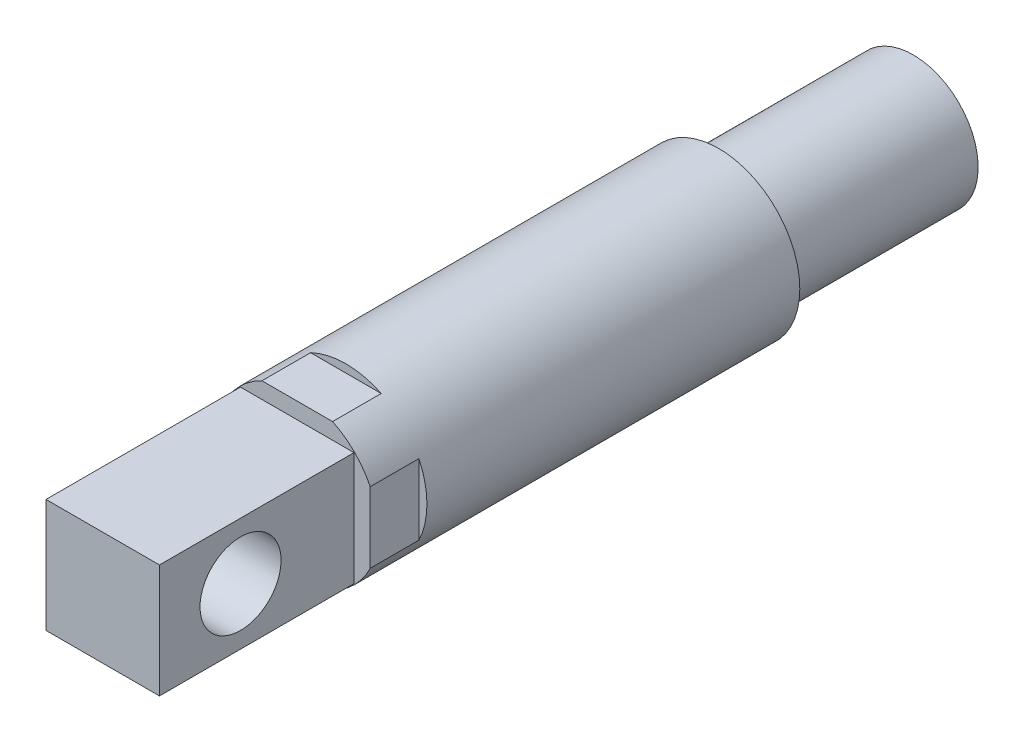
from build123d import *

# Parameters (mm, degrees)
ESQUISSE1_R             = 5
BOSS_EXTRU_2_DEPTH      = 70
ESQUISSE2_R             = 3.5
BOSS_EXTRU_3_DEPTH      = 12
ESQUISSE4_R             = 15
BOSS_EXTRU_5_DEPTH      = 5
ESQUISSE5_R             = 3.5
BOSS_EXTRU_6_DEPTH      = 12
ENL_V_MAT_EXTRU_1_DEPTH = 12
ESQUISSE7_R             = 15
ENL_V_MAT_EXTRU_2_DEPTH = 47
ESQUISSE8_W             = 9
ESQUISSE8_H             = 9
BOSS_EXTRU_7_DEPTH      = 5
ESQUISSE9_W             = 10
ESQUISSE9_H             = 10
ESQUISSE9_W_2           = 9
ESQUISSE9_H_2           = 9
ENL_V_MAT_EXTRU_3_DEPTH = 12
ESQUISSE10_W            = 9
ESQUISSE10_H            = 9
BOSS_EXTRU_8_DEPTH      = 7
ESQUISSE11_W            = 9
ESQUISSE11_H            = 9
ENL_V_MAT_EXTRU_4_DEPTH = 4
ESQUISSE13_W            = 9
ESQUISSE13_H            = 9
BOSS_EXTRU_9_DEPTH      = 12
ESQUISSE14_W            = 9
ESQUISSE14_H            = 9
ESQUISSE14_W_2          = 7
ESQUISSE14_H_2          = 7
ENL_V_MAT_EXTRU_5_DEPTH = 12
ESQUISSE15_R            = 2.5
ENL_V_MAT_EXTRU_6_DEPTH = 12
ESQUISSE16_R            = 4
BOSS_EXTRU_10_DEPTH     = 12


with BuildPart() as part:
    # Esquisse1 → Boss.-Extru.2 (new body)
    with BuildSketch(Plane.XY):
        Circle(ESQUISSE1_R)
    extrude(amount=BOSS_EXTRU_2_DEPTH)

    # Esquisse2 → Boss.-Extru.3 (add)
    with BuildSketch(Plane(origin=(0, 0, 0), x_dir=(-1, 0, 0), z_dir=(0, 0, -1))):
        Circle(ESQUISSE2_R)
    extrude(amount=BOSS_EXTRU_3_DEPTH)

    # Esquisse4 → Boss.-Extru.5 (add)
    with BuildSketch(Plane.XY.offset(70)):
        Circle(ESQUISSE4_R)
    extrude(amount=-BOSS_EXTRU_5_DEPTH)

    # Esquisse5 → Boss.-Extru.6 (add)
    with BuildSketch(Plane.XY.offset(70)):
        Circle(ESQUISSE5_R)
    extrude(amount=BOSS_EXTRU_6_DEPTH)

    # Esquisse6 → Enlèv. mat.-Extru.1 (cut)
    with BuildSketch(Plane.XY.offset(70)):
        with BuildLine():
            Line((-6.262893089, 8.172072336), (-7.499435292, 12.990707074))
            ThreePointArc((-7.499435292, 12.990707074), (-9.123657799, 11.90625333), (-10.593218546, 10.619968024))
            Line((-10.593218546, 10.619968024), (-6.262893089, 8.172072336))
        make_face()
        with BuildLine():
            Line((-8.152402023, 6.270263162), (-10.606442664, 10.606760769))
            ThreePointArc((-10.606442664, 10.606760769), (-11.894621233, 9.138817524), (-12.981158937, 7.515950549))
            Line((-12.981158937, 7.515950549), (-8.152402023, 6.270263162))
        make_face()
        with BuildLine():
            Line((-9.499942261, 3.951679007), (-12.981158937, 7.515950549))
            ThreePointArc((-12.981158937, 7.515950549), (-13.849269023, 5.761748652), (-14.481582106, 3.909447494))
            Line((-14.481582106, 3.909447494), (-9.499942261, 3.951679007))
        make_face()
        with BuildLine():
            Line((-10.188028074, 1.356459322), (-14.486441985, 3.891400598))
            ThreePointArc((-14.486441985, 3.891400598), (-14.869805294, 1.972027008), (-14.999987869, 0.0190767))
            Line((-14.999987869, 0.0190767), (-10.188028074, 1.356459322))
        make_face()
        with BuildLine():
            ThreePointArc((-14.999987869, -0.0190767), (-14.869805294, -1.972027008), (-14.486441985, -3.891400598))
            Line((-14.486441985, -3.891400598), (-10.188028074, -1.356459322))
            Line((-10.188028074, -1.356459322), (-14.999987869, -0.0190767))
        make_face()
        with BuildLine():
            Line((-9.499942261, -3.951679007), (-14.481582106, -3.909447494))
            ThreePointArc((-14.481582106, -3.909447494), (-13.849269023, -5.761748652), (-12.981158937, -7.515950549))
            Line((-12.981158937, -7.515950549), (-9.499942261, -3.951679007))
        make_face()
        with BuildLine():
            Line((-8.152402023, -6.270263162), (-12.981158937, -7.515950549))
            ThreePointArc((-12.981158937, -7.515950549), (-11.894621233, -9.138817524), (-10.606442664, -10.606760769))
            Line((-10.606442664, -10.606760769), (-8.152402023, -6.270263162))
        make_face()
        with BuildLine():
            Line((-6.262893089, -8.172072336), (-10.593218546, -10.619968024))
            ThreePointArc((-10.593218546, -10.619968024), (-9.123657799, -11.90625333), (-7.499435292, -12.990707074))
            Line((-7.499435292, -12.990707074), (-6.262893089, -8.172072336))
        make_face()
        with BuildLine():
            Line((-3.939593974, -9.504960245), (-7.499435292, -12.990707074))
            ThreePointArc((-7.499435292, -12.990707074), (-5.744130769, -13.8565855), (-3.891026946, -14.486542352))
            Line((-3.891026946, -14.486542352), (-3.939593974, -9.504960245))
        make_face()
        with BuildLine():
            Line((-1.343501295, -10.189744953), (-3.872973884, -14.491379275))
            ThreePointArc((-3.872973884, -14.491379275), (-1.953114292, -14.872301253), (0, -15))
            Line((0, -15), (-1.343501295, -10.189744953))
        make_face()
        with BuildLine():
            ThreePointArc((0, -15), (1.953114292, -14.872301253), (3.872973884, -14.491379275))
            Line((3.872973884, -14.491379275), (1.343501295, -10.189744953))
            Line((1.343501295, -10.189744953), (0, -15))
        make_face()
        with BuildLine():
            ThreePointArc((3.891026946, -14.486542352), (5.744130769, -13.8565855), (7.499435292, -12.990707074))
            Line((7.499435292, -12.990707074), (3.939593974, -9.504960245))
            Line((3.939593974, -9.504960245), (3.891026946, -14.486542352))
        make_face()
        with BuildLine():
            ThreePointArc((7.499435292, -12.990707074), (9.123657799, -11.90625333), (10.593218546, -10.619968024))
            Line((10.593218546, -10.619968024), (6.262893089, -8.172072336))
            Line((6.262893089, -8.172072336), (7.499435292, -12.990707074))
        make_face()
        with BuildLine():
            ThreePointArc((10.606442664, -10.606760769), (11.894621233, -9.138817524), (12.981158937, -7.515950549))
            Line((12.981158937, -7.515950549), (8.152402023, -6.270263162))
            Line((8.152402023, -6.270263162), (10.606442664, -10.606760769))
        make_face()
        with BuildLine():
            ThreePointArc((12.981158937, -7.515950549), (13.849269023, -5.761748652), (14.481582106, -3.909447494))
            Line((14.481582106, -3.909447494), (9.499942261, -3.951679007))
            Line((9.499942261, -3.951679007), (12.981158937, -7.515950549))
        make_face()
        with BuildLine():
            ThreePointArc((15, 0), (14.999996967, 0.009538352), (14.999987869, 0.0190767))
            Line((14.999987869, 0.0190767), (10.159352957, -1.339548494))
            Line((10.159352957, -1.339548494), (14.486441985, -3.891400598))
            ThreePointArc((14.486441985, -3.891400598), (14.87105628, -1.962571047), (15, 0))
        make_face()
        with BuildLine():
            ThreePointArc((14.999987869, 0.0190767), (14.869805294, 1.972027008), (14.486441985, 3.891400598))
            Line((14.486441985, 3.891400598), (10.188028074, 1.356459322))
            Line((10.188028074, 1.356459322), (14.999987869, 0.0190767))
        make_face()
        with BuildLine():
            ThreePointArc((14.481582106, 3.909447494), (13.849269023, 5.761748652), (12.981158937, 7.515950549))
            Line((12.981158937, 7.515950549), (9.499942261, 3.951679007))
            Line((9.499942261, 3.951679007), (14.481582106, 3.909447494))
        make_face()
        with BuildLine():
            ThreePointArc((12.981158937, 7.515950549), (11.894621233, 9.138817524), (10.606442664, 10.606760769))
            Line((10.606442664, 10.606760769), (8.152402023, 6.270263162))
            Line((8.152402023, 6.270263162), (12.981158937, 7.515950549))
        make_face()
        with BuildLine():
            ThreePointArc((10.593218546, 10.619968024), (9.123657799, 11.90625333), (7.499435292, 12.990707074))
            Line((7.499435292, 12.990707074), (6.262893089, 8.172072336))
            Line((6.262893089, 8.172072336), (10.593218546, 10.619968024))
        make_face()
        with BuildLine():
            ThreePointArc((7.499435292, 12.990707074), (5.744130769, 13.8565855), (3.891026946, 14.486542352))
            Line((3.891026946, 14.486542352), (3.939593974, 9.504960245))
            Line((3.939593974, 9.504960245), (7.499435292, 12.990707074))
        make_face()
        with BuildLine():
            ThreePointArc((3.872973884, 14.491379275), (1.953114292, 14.872301253), (0, 15))
            Line((0, 15), (1.343501295, 10.189744953))
            Line((1.343501295, 10.189744953), (3.872973884, 14.491379275))
        make_face()
        with BuildLine():
            Line((-1.343501295, 10.189744953), (0, 15))
            ThreePointArc((0, 15), (-1.953114292, 14.872301253), (-3.872973884, 14.491379275))
            Line((-3.872973884, 14.491379275), (-1.343501295, 10.189744953))
        make_face()
        with BuildLine():
            Line((-3.939593974, 9.504960245), (-3.891026946, 14.486542352))
            ThreePointArc((-3.891026946, 14.486542352), (-5.744130769, 13.8565855), (-7.499435292, 12.990707074))
            Line((-7.499435292, 12.990707074), (-3.939593974, 9.504960245))
        make_face()
    extrude(amount=-ENL_V_MAT_EXTRU_1_DEPTH, mode=Mode.SUBTRACT)

    # Esquisse7 → Enlèv. mat.-Extru.2 (cut)
    with BuildSketch(Plane.XY.offset(82)):
        Circle(ESQUISSE7_R)
    extrude(amount=-ENL_V_MAT_EXTRU_2_DEPTH, mode=Mode.SUBTRACT)

    # Esquisse8 → Boss.-Extru.7 (add)
    with BuildSketch(Plane.XY.offset(35)):
        Rectangle(ESQUISSE8_W, ESQUISSE8_H)
    extrude(amount=-BOSS_EXTRU_7_DEPTH)

    # Esquisse9 → Enlèv. mat.-Extru.3 (cut)
    with BuildSketch(Plane.XY.offset(35)):
        Rectangle(ESQUISSE9_W, ESQUISSE9_H)
        Rectangle(ESQUISSE9_W_2, ESQUISSE9_H_2, mode=Mode.SUBTRACT)
    extrude(amount=-ENL_V_MAT_EXTRU_3_DEPTH, mode=Mode.SUBTRACT)

    # Esquisse10 → Boss.-Extru.8 (add)
    with BuildSketch(Plane.XY.offset(35)):
        Rectangle(ESQUISSE10_W, ESQUISSE10_H)
    extrude(amount=BOSS_EXTRU_8_DEPTH)

    # Esquisse11 → Enlèv. mat.-Extru.4 (cut)
    with BuildSketch(Plane.XY.offset(42)):
        Rectangle(ESQUISSE11_W, ESQUISSE11_H)
    extrude(amount=-ENL_V_MAT_EXTRU_4_DEPTH, mode=Mode.SUBTRACT)

    # Esquisse13 → Boss.-Extru.9 (add)
    with BuildSketch(Plane.XY.offset(38)):
        Rectangle(ESQUISSE13_W, ESQUISSE13_H)
    extrude(amount=-BOSS_EXTRU_9_DEPTH)

    # Esquisse14 → Enlèv. mat.-Extru.5 (cut)
    with BuildSketch(Plane.XY.offset(38)):
        Rectangle(ESQUISSE14_W, ESQUISSE14_H)
        Rectangle(ESQUISSE14_W_2, ESQUISSE14_H_2, mode=Mode.SUBTRACT)
    extrude(amount=-ENL_V_MAT_EXTRU_5_DEPTH, mode=Mode.SUBTRACT)

    # Esquisse15 → Enlèv. mat.-Extru.6 (cut)
    with BuildSketch(Plane(origin=(3.5, 0, 0), x_dir=(0, 0, -1), z_dir=(1, 0, 0))):
        with Locations((-33, 0)):
            Circle(ESQUISSE15_R)
    extrude(amount=-ENL_V_MAT_EXTRU_6_DEPTH, mode=Mode.SUBTRACT)

    # Esquisse16 → Boss.-Extru.10 (add)
    with BuildSketch(Plane(origin=(0, 0, -12), x_dir=(-1, 0, 0), z_dir=(0, 0, -1))):
        Circle(ESQUISSE16_R)
    extrude(amount=-BOSS_EXTRU_10_DEPTH)


solid = part.part
